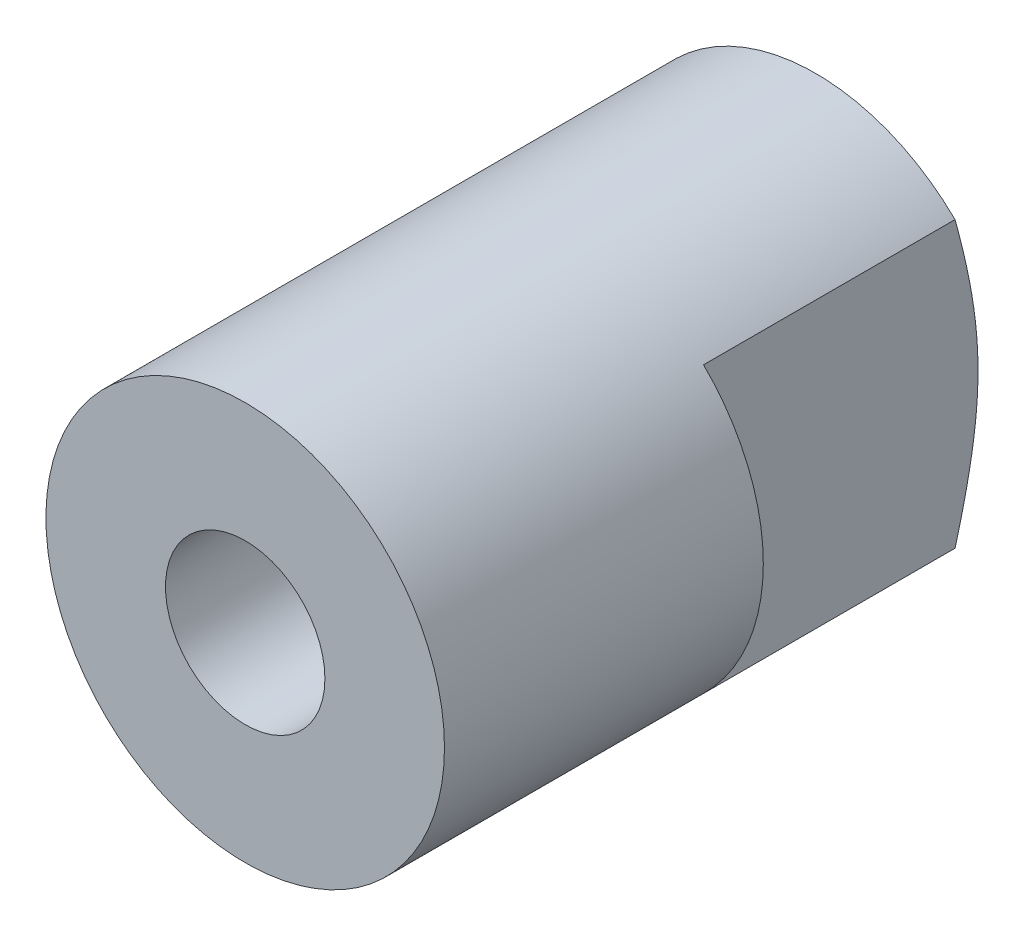
from build123d import *

# Parameters (mm, degrees)
SKETCH1_R                    = 2.5
BOSS_EXTRUDE1_DEPTH          = 8
SKETCH6_R                    = 0.25
CUT_EXTRUDE1_DEPTH           = 1
CHAMFER1_SIZE                = 2.2
CHAMFER1_SIZE2               = 0.844500877
SKETCH7_W                    = 1.688266385
SKETCH7_H                    = 5.007188161
CUT_EXTRUDE2_DEPTH           = 5
F_2_0_2_DIAMETER_HOLE1_D     = 2
F_2_0_2_DIAMETER_HOLE1_DEPTH = 7.05
F_2_0_2_DIAMETER_HOLE1_TIP   = 0.600860619


with BuildPart() as part:
    # Sketch1 → Boss-Extrude1 (new body)
    with BuildSketch(Plane.XY):
        Circle(SKETCH1_R)
    extrude(amount=BOSS_EXTRUDE1_DEPTH)

    # Sketch6 → Cut-Extrude1 (cut)
    with BuildSketch(Plane(origin=(0, 0, 0), x_dir=(-1, 0, 0), z_dir=(0, 0, -1))):
        Circle(SKETCH6_R)
    extrude(amount=-CUT_EXTRUDE1_DEPTH, mode=Mode.SUBTRACT)

    # Chamfer1
    chamfer1_edges = [part.edges().sort_by_distance(p)[0] for p in [
        (-2.5, 0, 0),
    ]]
    chamfer1_side = [part.faces().sort_by_distance(p)[0] for p in [
        (-2.429289322, 0, 0),
    ]]
    chamfer(chamfer1_edges, length=CHAMFER1_SIZE, length2=CHAMFER1_SIZE2, reference=chamfer1_side[0])

    # Sketch7 → Cut-Extrude2 (cut, symmetric)
    with BuildSketch(Plane(origin=(0, 0, 0), x_dir=(1, 0, 0), z_dir=(0, 1, 0))):
        with Locations((2.594133193, -1.496405919)):
            Rectangle(SKETCH7_W, SKETCH7_H)
    cut_extrude2 = extrude(amount=CUT_EXTRUDE2_DEPTH, both=True, mode=Mode.SUBTRACT)

    # Mirror1: Cut-Extrude2 across plane
    add(cut_extrude2.mirror(Plane(origin=(0, 0, 0), x_dir=(0, 0, 1), z_dir=(1, 0, 0))), mode=Mode.SUBTRACT)

    # Ø2.0 (2) Diameter Hole1
    with Locations(Plane.XY.offset(8)):
        with Locations((0, 0)):
            Hole(F_2_0_2_DIAMETER_HOLE1_D / 2, depth=F_2_0_2_DIAMETER_HOLE1_DEPTH)
            with Locations((0, 0, -(F_2_0_2_DIAMETER_HOLE1_DEPTH + F_2_0_2_DIAMETER_HOLE1_TIP / 2))):  # 118° drill point
                Cone(0, F_2_0_2_DIAMETER_HOLE1_D / 2, F_2_0_2_DIAMETER_HOLE1_TIP, mode=Mode.SUBTRACT)


solid = part.part
